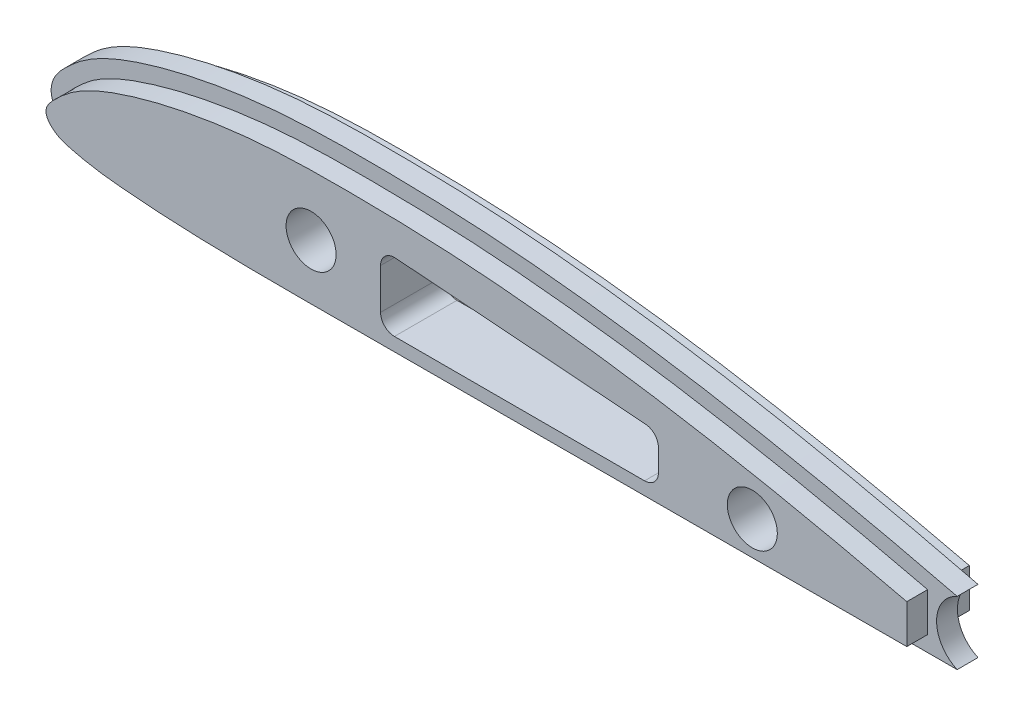
from build123d import *

# Parameters (mm, degrees)
SKETCH3_R               = 3.5
BOSS_EXTRUDE1_DEPTH     = 4
BOSS_EXTRUDE2_DEPTH     = 3
CUT_EXTRUDE1_DEPTH      = 5.0000001
BOSS_EXTRUDE4_DEPTH     = 3
BOSS_EXTRUDE5_DEPTH     = 3
SKETCH9_R               = 3.6
CUT_EXTRUDE2_DEPTH      = 9
CUT_EXTRUDE3_DEPTH      = 4.0000001
CUT_EXTRUDE3_DEPTH_BACK = 7.0000001
SKETCH11_W              = 2.167917732
SKETCH11_H              = 7.161417813
CUT_EXTRUDE6_DEPTH      = 3
SKETCH12_W              = 2.167917732
SKETCH12_H              = 7.161417813
CUT_EXTRUDE7_DEPTH      = 3
CUT_EXTRUDE9_DEPTH      = 3
CUT_EXTRUDE10_DEPTH     = 3


with BuildPart() as part:
    # Sketch3 → Boss-Extrude1 (new body)
    with BuildSketch(Plane.XY.offset(36)):
        with BuildLine():
            Line((-17.507687929, 7.098598456), (-17.507687929, -2.034015736))
            add(Edge.make_bspline(
                [(-17.507687929, -2.034015736), (-17.59710145, -2.034174747), (-23.946393618, -2.045470231), (-36.555421714, -2.068518218), (-52.204726192, -2.095858601), (-64.724293502, -2.119042278), (-74.11406586, -2.136122756), (-83.503466045, -2.154479254), (-92.895603229, -2.167303148), (-100.715063704, -2.181150618), (-106.975936848, -2.203805028), (-111.680744165, -2.207091169), (-116.392596798, -2.178542612), (-121.113091521, -2.10023992), (-125.84321921, -1.945988731), (-129.78756227, -1.737082235), (-132.952810944, -1.498805031), (-135.299204798, -1.298598743), (-137.306246818, -1.094956387), (-138.941018346, -0.85883569), (-140.167865234, -0.63812983), (-141.388343948, -0.367024517), (-142.50781202, -0.106908319), (-143.619879769, 0.187407287), (-144.573251274, 0.566727136), (-145.318542092, 0.960640819), (-146.004517518, 1.453076063), (-146.618651979, 2.013419046), (-147.105315384, 2.593490807), (-147.457347193, 3.170908063), (-147.683742099, 3.645438142), (-147.875151792, 4.283340334), (-147.943241407, 4.925327448), (-147.890465513, 5.612652503), (-147.673433661, 6.400721917), (-147.29794551, 7.135095795), (-146.804153318, 7.818485275), (-146.309832983, 8.377271541), (-145.667480337, 9.017060049), (-144.93409978, 9.693990784), (-143.927837205, 10.555388137), (-142.850562114, 11.332410028), (-141.728789168, 12.023225149), (-140.222179028, 12.824770903), (-138.312181755, 13.673340422), (-136.004938901, 14.51973015), (-133.704333622, 15.252810704), (-131.381472985, 15.913774987), (-128.258181422, 16.687146597), (-124.336161455, 17.472514733), (-119.600616416, 18.190219581), (-114.823127608, 18.671875466), (-108.462225557, 19.005447079), (-100.578503662, 19.032147683), (-91.132523886, 18.843085355), (-81.669646013, 18.277649651), (-69.12546009, 17.049566382), (-53.530845898, 14.827338822), (-35.297374717, 11.277627721), (-23.330991543, 8.527862214), (-17.507687929, 7.098598456)],
                knots=[0.065344951, 0.065344951, 0.065344951, 0.065344951, 0.066237675, 0.128737675, 0.191237675, 0.222487675, 0.253737675, 0.284987675, 0.316237675, 0.347487675, 0.363112675, 0.378737675, 0.394362675, 0.409987675, 0.425612675, 0.441237675, 0.449050175, 0.456862675, 0.464675175, 0.468581425, 0.472487675, 0.476393925, 0.480300175, 0.484206425, 0.48615955, 0.488112675, 0.4900658, 0.492018925, 0.49397205, 0.494948613, 0.495925175, 0.496901738, 0.4978783, 0.498854863, 0.499831425, 0.50178455, 0.503737675, 0.5056908, 0.507643925, 0.511550175, 0.515456425, 0.519362675, 0.523268925, 0.527175175, 0.534987675, 0.542800175, 0.550612675, 0.558425175, 0.566237675, 0.581862675, 0.597487675, 0.613112675, 0.628737675, 0.659987675, 0.691237675, 0.722487675, 0.753737675, 0.816237675, 0.878737675, 0.938392724, 0.938392724, 0.938392724, 0.938392724], degree=3))
        make_face()
        with Locations((-107.507687929, 7.999404624)):
            Circle(SKETCH3_R, mode=Mode.SUBTRACT)
    extrude(amount=BOSS_EXTRUDE1_DEPTH)

    # Sketch4 → Boss-Extrude2 (add)
    with BuildSketch(Plane.XY.offset(40)):
        with BuildLine():
            Line((-19.507687929, -0.037521046), (-19.507687929, 5.529173109))
            add(Edge.make_bspline(
                [(-19.507687929, 5.529173109), (-20.443770828, 5.756777807), (-22.351826136, 6.215749211), (-27.174061996, 7.349019512), (-33.978074235, 8.87255681), (-44.677852951, 11.073938952), (-57.330755001, 13.372822355), (-71.009548629, 15.243863732), (-80.79958979, 16.181661516), (-89.608767887, 16.757734528), (-95.488269025, 16.949372948), (-102.350261409, 17.013236255), (-107.257957682, 17.003677137), (-112.169157697, 16.8305791), (-117.092255682, 16.461150925), (-121.035843273, 15.973066987), (-125.976922577, 15.131238489), (-129.943886321, 14.259599111), (-133.888928179, 13.113562747), (-136.893257554, 12.098280948), (-139.389650859, 11.029019517), (-141.383729174, 9.919905225), (-142.798550192, 8.917902508), (-143.868342813, 7.957464114), (-144.686348929, 7.1840502), (-145.20850207, 6.61597777), (-145.597806824, 6.064290391), (-145.812968494, 5.627863129), (-145.949608602, 5.110451824), (-145.917074686, 4.68114777), (-145.781262852, 4.303708219), (-145.631722987, 4.002112103), (-145.322122744, 3.5592561), (-144.843020742, 3.084633274), (-144.08911256, 2.535035347), (-143.008167388, 2.073432454), (-141.620225791, 1.743003025), (-140.162356424, 1.39981262), (-138.700027853, 1.124107097), (-136.748239015, 0.847974469), (-134.301943532, 0.621510039), (-131.368400158, 0.379313114), (-125.498015236, 0.006362829), (-115.695266078, -0.245453373), (-101.968694839, -0.177054014), (-89.220643014, -0.164335562), (-73.530096937, -0.135235118), (-57.83955343, -0.106214113), (-42.149001448, -0.07780996), (-31.361749043, -0.05939132), (-24.468419414, -0.046267759), (-20.517064545, -0.039291678), (-19.507687929, -0.037521046)],
                knots=[0.070561921, 0.070561921, 0.070561921, 0.070561921, 0.080180377, 0.09015591, 0.120020101, 0.149793491, 0.199219015, 0.248395636, 0.287604023, 0.297393127, 0.336534715, 0.346322474, 0.365907652, 0.385530879, 0.395375762, 0.415192461, 0.425184025, 0.445412191, 0.455710779, 0.466190959, 0.477054504, 0.482786727, 0.488945835, 0.494316033, 0.497126416, 0.500187368, 0.502000869, 0.503849971, 0.505020137, 0.507317905, 0.507986558, 0.509023586, 0.510668219, 0.513358348, 0.515715812, 0.519949385, 0.524973188, 0.5299544, 0.534903202, 0.539824123, 0.549630394, 0.559425369, 0.569214167, 0.608355933, 0.657307127, 0.70626328, 0.735636871, 0.813966735, 0.862922864, 0.892296527, 0.921670208, 0.931748157, 0.931748157, 0.931748157, 0.931748157], degree=3))
        make_face()
    extrude(amount=BOSS_EXTRUDE2_DEPTH)

    # Sketch6 → Cut-Extrude1 (cut, through all)
    with BuildSketch(Plane.XY.offset(40)):
        with BuildLine():
            Line((-17.507687929, -2.034015736), (-17.507687929, 7.098598456))
            add(Edge.make_bspline(
                [(-17.507687929, 7.098598456), (-23.330991543, 8.527862214), (-35.297374717, 11.277627721), (-53.530845898, 14.827338822), (-69.12546009, 17.049566382), (-81.669646013, 18.277649651), (-91.132523886, 18.843085355), (-100.578503662, 19.032147683), (-108.462225557, 19.005447079), (-114.823127608, 18.671875466), (-119.600616416, 18.190219581), (-124.336161455, 17.472514733), (-128.258181422, 16.687146597), (-131.381472985, 15.913774987), (-133.704333622, 15.252810704), (-136.004938901, 14.51973015), (-138.312181755, 13.673340422), (-140.222179028, 12.824770903), (-141.728789168, 12.023225149), (-142.850562114, 11.332410028), (-143.927837205, 10.555388137), (-144.93409978, 9.693990784), (-145.667480337, 9.017060049), (-146.309832983, 8.377271541), (-146.804153318, 7.818485275), (-147.29794551, 7.135095795), (-147.673433661, 6.400721917), (-147.890465513, 5.612652503), (-147.943241407, 4.925327448), (-147.875151792, 4.283340334), (-147.683742099, 3.645438142), (-147.457347193, 3.170908063), (-147.105315384, 2.593490807), (-146.618651979, 2.013419046), (-146.004517518, 1.453076063), (-145.318542092, 0.960640819), (-144.573251274, 0.566727136), (-143.619879769, 0.187407287), (-142.50781202, -0.106908319), (-141.388343948, -0.367024517), (-140.167865234, -0.63812983), (-138.941018346, -0.85883569), (-137.306246818, -1.094956387), (-135.299204798, -1.298598743), (-132.952810944, -1.498805031), (-129.78756227, -1.737082235), (-125.84321921, -1.945988731), (-121.113091521, -2.10023992), (-116.392596798, -2.178542612), (-111.680744165, -2.207091169), (-106.975936848, -2.203805028), (-100.715063704, -2.181150618), (-92.895603229, -2.167303148), (-83.503466045, -2.154479254), (-74.11406586, -2.136122756), (-64.724293502, -2.119042278), (-52.204726192, -2.095858601), (-36.555421714, -2.068518218), (-23.946393618, -2.045470231), (-17.59710145, -2.034174747), (-17.507687929, -2.034015736)],
                knots=[0.065344951, 0.065344951, 0.065344951, 0.065344951, 0.125, 0.1875, 0.25, 0.28125, 0.3125, 0.34375, 0.375, 0.390625, 0.40625, 0.421875, 0.4375, 0.4453125, 0.453125, 0.4609375, 0.46875, 0.4765625, 0.48046875, 0.484375, 0.48828125, 0.4921875, 0.49609375, 0.498046875, 0.5, 0.501953125, 0.50390625, 0.504882812, 0.505859375, 0.506835938, 0.5078125, 0.508789062, 0.509765625, 0.51171875, 0.513671875, 0.515625, 0.517578125, 0.51953125, 0.5234375, 0.52734375, 0.53125, 0.53515625, 0.5390625, 0.546875, 0.5546875, 0.5625, 0.578125, 0.59375, 0.609375, 0.625, 0.640625, 0.65625, 0.6875, 0.71875, 0.75, 0.78125, 0.8125, 0.875, 0.9375, 0.938392724, 0.938392724, 0.938392724, 0.938392724], degree=3))
        make_face()
    extrude(amount=-CUT_EXTRUDE1_DEPTH, mode=Mode.SUBTRACT)

    # Sketch7 → Boss-Extrude4 (add)
    with BuildSketch(Plane(origin=(0, 0, 40), x_dir=(-1, 0, 0), z_dir=(0, 0, -1))):
        with BuildLine():
            Line((17.507687929, 7.098598456), (17.507687929, -2.034015736))
            add(Edge.make_bspline(
                [(17.507687929, -2.034015736), (17.59710145, -2.034174747), (23.946393618, -2.045470231), (36.555421714, -2.068518218), (52.204726192, -2.095858601), (64.724293502, -2.119042278), (74.11406586, -2.136122756), (83.503466045, -2.154479254), (92.895603229, -2.167303148), (100.715063704, -2.181150618), (106.975936848, -2.203805028), (111.680744165, -2.207091169), (116.392596798, -2.178542612), (121.113091521, -2.10023992), (125.84321921, -1.945988731), (129.78756227, -1.737082235), (132.952810944, -1.498805031), (135.299204798, -1.298598743), (137.306246818, -1.094956387), (138.941018346, -0.85883569), (140.167865234, -0.63812983), (141.388343948, -0.367024517), (142.50781202, -0.106908319), (143.619879769, 0.187407287), (144.573251274, 0.566727136), (145.318542092, 0.960640819), (146.004517518, 1.453076063), (146.618651979, 2.013419046), (147.105315384, 2.593490807), (147.457347193, 3.170908063), (147.683742099, 3.645438142), (147.875151792, 4.283340334), (147.943241407, 4.925327448), (147.890465513, 5.612652503), (147.673433661, 6.400721917), (147.29794551, 7.135095795), (146.804153318, 7.818485275), (146.309832983, 8.377271541), (145.667480337, 9.017060049), (144.93409978, 9.693990784), (143.927837205, 10.555388137), (142.850562114, 11.332410028), (141.728789168, 12.023225149), (140.222179028, 12.824770903), (138.312181755, 13.673340422), (136.004938901, 14.51973015), (133.704333622, 15.252810704), (131.381472985, 15.913774987), (128.258181422, 16.687146597), (124.336161455, 17.472514733), (119.600616416, 18.190219581), (114.823127608, 18.671875466), (108.462225557, 19.005447079), (100.578503662, 19.032147683), (91.132523886, 18.843085355), (81.669646013, 18.277649651), (69.12546009, 17.049566382), (53.530845898, 14.827338822), (35.297374717, 11.277627721), (23.330991543, 8.527862214), (17.507687929, 7.098598456)],
                knots=[0.065344951, 0.065344951, 0.065344951, 0.065344951, 0.066237675, 0.128737675, 0.191237675, 0.222487675, 0.253737675, 0.284987675, 0.316237675, 0.347487675, 0.363112675, 0.378737675, 0.394362675, 0.409987675, 0.425612675, 0.441237675, 0.449050175, 0.456862675, 0.464675175, 0.468581425, 0.472487675, 0.476393925, 0.480300175, 0.484206425, 0.48615955, 0.488112675, 0.4900658, 0.492018925, 0.49397205, 0.494948613, 0.495925175, 0.496901738, 0.4978783, 0.498854863, 0.499831425, 0.50178455, 0.503737675, 0.5056908, 0.507643925, 0.511550175, 0.515456425, 0.519362675, 0.523268925, 0.527175175, 0.534987675, 0.542800175, 0.550612675, 0.558425175, 0.566237675, 0.581862675, 0.597487675, 0.613112675, 0.628737675, 0.659987675, 0.691237675, 0.722487675, 0.753737675, 0.816237675, 0.878737675, 0.938392724, 0.938392724, 0.938392724, 0.938392724], degree=3))
        make_face()
    extrude(amount=BOSS_EXTRUDE4_DEPTH)

    # Sketch8 → Boss-Extrude5 (add)
    with BuildSketch(Plane(origin=(0, 0, 37), x_dir=(-1, 0, 0), z_dir=(0, 0, -1))):
        with BuildLine():
            Line((19.507687929, 5.529173109), (19.507687929, -0.037521046))
            add(Edge.make_bspline(
                [(19.507687929, -0.037521046), (20.517064545, -0.039291678), (24.468419414, -0.046267759), (31.361749043, -0.05939132), (42.149001448, -0.07780996), (57.83955343, -0.106214113), (73.530096937, -0.135235118), (89.220643014, -0.164335562), (101.968694839, -0.177054014), (115.695266078, -0.245453373), (125.498015236, 0.006362829), (131.368400158, 0.379313114), (134.301943532, 0.621510039), (136.748239015, 0.847974469), (138.700027853, 1.124107097), (140.162356424, 1.39981262), (141.620225791, 1.743003025), (143.008167388, 2.073432454), (144.08911256, 2.535035347), (144.843020742, 3.084633274), (145.322122744, 3.5592561), (145.631722987, 4.002112103), (145.781262852, 4.303708219), (145.917074686, 4.68114777), (145.949608602, 5.110451824), (145.812968494, 5.627863129), (145.597806824, 6.064290391), (145.20850207, 6.61597777), (144.686348929, 7.1840502), (143.868342813, 7.957464114), (142.798550192, 8.917902508), (141.383729174, 9.919905225), (139.389650859, 11.029019517), (136.893257554, 12.098280948), (133.888928179, 13.113562747), (129.943886321, 14.259599111), (125.976922577, 15.131238489), (121.035843273, 15.973066987), (117.092255682, 16.461150925), (112.169157697, 16.8305791), (107.257957682, 17.003677137), (102.350261409, 17.013236255), (95.488269025, 16.949372948), (89.608767887, 16.757734528), (80.79958979, 16.181661516), (71.009548629, 15.243863732), (57.330755001, 13.372822355), (44.677852951, 11.073938952), (33.978074235, 8.87255681), (27.174061996, 7.349019512), (22.351826136, 6.215749211), (20.443770828, 5.756777807), (19.507687929, 5.529173109)],
                knots=[0.070561921, 0.070561921, 0.070561921, 0.070561921, 0.08063987, 0.110013551, 0.139387214, 0.188343343, 0.266673206, 0.296046798, 0.34500295, 0.393954145, 0.43309591, 0.442884709, 0.452679683, 0.462485955, 0.467406876, 0.472355677, 0.47733689, 0.482360692, 0.486594266, 0.48895173, 0.491641859, 0.493286492, 0.49432352, 0.494992173, 0.497289941, 0.498460107, 0.500309209, 0.50212271, 0.505183661, 0.507994045, 0.513364243, 0.519523351, 0.525255574, 0.536119119, 0.546599299, 0.556897887, 0.577126052, 0.587117617, 0.606934315, 0.616779199, 0.636402426, 0.655987604, 0.665775363, 0.704916951, 0.714706054, 0.753914441, 0.803091062, 0.852516587, 0.882289976, 0.912154167, 0.922129701, 0.931748157, 0.931748157, 0.931748157, 0.931748157], degree=3))
        make_face()
    extrude(amount=BOSS_EXTRUDE5_DEPTH)

    # Sketch9 → Cut-Extrude2 (cut)
    with BuildSketch(Plane.XY.offset(43)):
        with Locations((-107.507687928, 7.999404624)):
            Circle(SKETCH9_R)
        with Locations((-43.993853989, 4.999404624)):
            Circle(SKETCH9_R)
        with BuildLine():
            Line((-59.507687929, 1.999404624), (-95.507687929, 1.999404624))
            ThreePointArc((-95.507687929, 1.999404624), (-96.921901491, 2.585191062), (-97.507687929, 3.999404624))
            Line((-97.507687929, 3.999404624), (-97.507687929, 9.843787512))
            ThreePointArc((-97.507687929, 9.843787512), (-96.867989404, 11.309932081), (-95.358108032, 11.838186132))
            Line((-95.358108032, 11.838186132), (-59.358108032, 9.138186132))
            ThreePointArc((-59.358108032, 9.138186132), (-58.04154336, 8.504088988), (-57.507687929, 7.143787512))
            Line((-57.507687929, 7.143787512), (-57.507687929, 3.999404624))
            ThreePointArc((-57.507687929, 3.999404624), (-58.093474366, 2.585191062), (-59.507687929, 1.999404624))
        make_face()
    extrude(amount=-CUT_EXTRUDE2_DEPTH, mode=Mode.SUBTRACT)

    # Sketch10 → Cut-Extrude3 (cut, two sides)
    with BuildSketch(Plane.XY.offset(40)) as cut_extrude3_sk:
        with BuildLine():
            Line((-17.507687928, 7.098598456), (-17.507687929, -2.034015736))
            ThreePointArc((-17.507687929, -2.034015736), (-20.470817902, 2.53229136), (-17.507687928, 7.098598456))
        make_face()
    extrude(amount=CUT_EXTRUDE3_DEPTH, mode=Mode.SUBTRACT)
    extrude(cut_extrude3_sk.sketch, amount=-CUT_EXTRUDE3_DEPTH_BACK, mode=Mode.SUBTRACT)

    # Sketch11 → Cut-Extrude6 (cut)
    with BuildSketch(Plane.XY.offset(43)):
        with Locations((-20.423729075, 3.042058791)):
            Rectangle(SKETCH11_W, SKETCH11_H)
    extrude(amount=-CUT_EXTRUDE6_DEPTH, mode=Mode.SUBTRACT)

    # Sketch12 → Cut-Extrude7 (cut)
    with BuildSketch(Plane(origin=(0, 0, 34), x_dir=(-1, 0, 0), z_dir=(0, 0, -1))):
        with Locations((20.423729075, 3.042058791)):
            Rectangle(SKETCH12_W, SKETCH12_H)
    extrude(amount=-CUT_EXTRUDE7_DEPTH, mode=Mode.SUBTRACT)

    # Sketch14 → Cut-Extrude9 (cut)
    with BuildSketch(Plane(origin=(0, 0, 34), x_dir=(-1, 0, 0), z_dir=(0, 0, -1))):
        with BuildLine():
            ThreePointArc((17.507687929, -2.034015736), (20.470817902, 2.53229136), (17.507687929, 7.098598456))
            add(Edge.make_bspline(
                [(17.507687929, -2.034015736), (17.59710145, -2.034174747), (23.946393618, -2.045470231), (36.555421714, -2.068518218), (52.204726192, -2.095858601), (64.724293502, -2.119042278), (74.11406586, -2.136122756), (83.503466045, -2.154479254), (92.895603229, -2.167303148), (100.715063704, -2.181150618), (106.975936848, -2.203805028), (111.680744165, -2.207091169), (116.392596798, -2.178542612), (121.113091521, -2.10023992), (125.84321921, -1.945988731), (129.78756227, -1.737082235), (132.952810944, -1.498805031), (135.299204798, -1.298598743), (137.306246818, -1.094956387), (138.941018346, -0.85883569), (140.167865234, -0.63812983), (141.388343948, -0.367024517), (142.50781202, -0.106908319), (143.619879769, 0.187407287), (144.573251274, 0.566727136), (145.318542092, 0.960640819), (146.004517518, 1.453076063), (146.618651979, 2.013419046), (147.105315384, 2.593490807), (147.457347193, 3.170908063), (147.683742099, 3.645438142), (147.875151792, 4.283340334), (147.943241407, 4.925327448), (147.890465513, 5.612652503), (147.673433661, 6.400721917), (147.29794551, 7.135095795), (146.804153318, 7.818485275), (146.309832983, 8.377271541), (145.667480337, 9.017060049), (144.93409978, 9.693990784), (143.927837205, 10.555388137), (142.850562114, 11.332410028), (141.728789168, 12.023225149), (140.222179028, 12.824770903), (138.312181755, 13.673340422), (136.004938901, 14.51973015), (133.704333622, 15.252810704), (131.381472985, 15.913774987), (128.258181422, 16.687146597), (124.336161455, 17.472514733), (119.600616416, 18.190219581), (114.823127608, 18.671875466), (108.462225557, 19.005447079), (100.578503662, 19.032147683), (91.132523886, 18.843085355), (81.669646013, 18.277649651), (69.12546009, 17.049566382), (53.530845898, 14.827338822), (35.297374717, 11.277627721), (23.330991543, 8.527862214), (17.507687929, 7.098598456)],
                knots=[0.065344951, 0.065344951, 0.065344951, 0.065344951, 0.066237675, 0.128737675, 0.191237675, 0.222487675, 0.253737675, 0.284987675, 0.316237675, 0.347487675, 0.363112675, 0.378737675, 0.394362675, 0.409987675, 0.425612675, 0.441237675, 0.449050175, 0.456862675, 0.464675175, 0.468581425, 0.472487675, 0.476393925, 0.480300175, 0.484206425, 0.48615955, 0.488112675, 0.4900658, 0.492018925, 0.49397205, 0.494948613, 0.495925175, 0.496901738, 0.4978783, 0.498854863, 0.499831425, 0.50178455, 0.503737675, 0.5056908, 0.507643925, 0.511550175, 0.515456425, 0.519362675, 0.523268925, 0.527175175, 0.534987675, 0.542800175, 0.550612675, 0.558425175, 0.566237675, 0.581862675, 0.597487675, 0.613112675, 0.628737675, 0.659987675, 0.691237675, 0.722487675, 0.753737675, 0.816237675, 0.878737675, 0.938392724, 0.938392724, 0.938392724, 0.938392724], degree=3))
        make_face()
        with BuildLine():
            Line((21.757687941, 5.81437266), (21.757687941, 0.208464097))
            add(Edge.make_bspline(
                [(21.757687941, 0.208464097), (27.435156831, 0.198237258), (39.245251816, 0.177014142), (57.188038047, 0.144947914), (72.519610371, 0.117067237), (84.784903853, 0.093118104), (93.983532581, 0.081910997), (103.183563193, 0.061634203), (110.848171863, 0.033556862), (116.977658443, 0.078635666), (121.573513778, 0.162320748), (126.165497012, 0.320816771), (129.988221505, 0.530667253), (133.040124441, 0.766581949), (135.330728918, 0.963132049), (137.608273151, 1.203102821), (139.485617274, 1.511700539), (140.97036599, 1.846575285), (142.092415878, 2.106767579), (143.178028805, 2.406656418), (144.178209294, 2.868921197), (145.025119587, 3.564950571), (145.677805283, 4.451173318), (145.704380786, 5.443632855), (145.106613017, 6.372987277), (144.337250241, 7.181558722), (143.494137795, 7.960434605), (142.637901868, 8.702728303), (141.422003019, 9.598127217), (139.782147224, 10.546292159), (137.704142654, 11.489019005), (135.562457811, 12.291719911), (132.655200729, 13.234227506), (128.968439239, 14.235896843), (124.473537708, 15.160153644), (119.939924555, 15.874264664), (115.378481833, 16.369087521), (109.269129835, 16.733040761), (101.609617277, 16.788804796), (92.417217291, 16.633004768), (83.240518594, 16.140996306), (74.087860096, 15.291600486), (64.961938249, 14.179657332), (52.841226577, 12.359280984), (38.420408642, 9.620569914), (27.088521553, 7.088063072), (21.757687941, 5.81437266)],
                knots=[0.076126811, 0.076126811, 0.076126811, 0.076126811, 0.132812569, 0.194042822, 0.255273076, 0.285888203, 0.31650333, 0.347118457, 0.377733584, 0.393041148, 0.408348711, 0.423656275, 0.438963838, 0.44661762, 0.454271402, 0.461925183, 0.469578965, 0.473405856, 0.477232747, 0.481059638, 0.484886529, 0.48871342, 0.49254031, 0.496367201, 0.500194092, 0.504020983, 0.507847874, 0.511674765, 0.515501656, 0.523155437, 0.530809219, 0.538463001, 0.546116783, 0.561424346, 0.57673191, 0.592039473, 0.607347037, 0.6226546, 0.653269727, 0.683884854, 0.714499981, 0.745115108, 0.775730235, 0.806345362, 0.867575616, 0.922322514, 0.922322514, 0.922322514, 0.922322514], degree=3))
        make_face(mode=Mode.SUBTRACT)
    extrude(amount=-CUT_EXTRUDE9_DEPTH, mode=Mode.SUBTRACT)

    # Sketch15 → Cut-Extrude10 (cut)
    with BuildSketch(Plane.XY.offset(43)):
        with BuildLine():
            ThreePointArc((-17.507687929, 7.098598456), (-20.470817902, 2.53229136), (-17.507687929, -2.034015736))
            add(Edge.make_bspline(
                [(-17.507687929, 7.098598456), (-23.330991543, 8.527862214), (-35.297374717, 11.277627721), (-53.530845898, 14.827338822), (-69.12546009, 17.049566382), (-81.669646013, 18.277649651), (-91.132523886, 18.843085355), (-100.578503662, 19.032147683), (-108.462225557, 19.005447079), (-114.823127608, 18.671875466), (-119.600616416, 18.190219581), (-124.336161455, 17.472514733), (-128.258181422, 16.687146597), (-131.381472985, 15.913774987), (-133.704333622, 15.252810704), (-136.004938901, 14.51973015), (-138.312181755, 13.673340422), (-140.222179028, 12.824770903), (-141.728789168, 12.023225149), (-142.850562114, 11.332410028), (-143.927837205, 10.555388137), (-144.93409978, 9.693990784), (-145.667480337, 9.017060049), (-146.309832983, 8.377271541), (-146.804153318, 7.818485275), (-147.29794551, 7.135095795), (-147.673433661, 6.400721917), (-147.890465513, 5.612652503), (-147.943241407, 4.925327448), (-147.875151792, 4.283340334), (-147.683742099, 3.645438142), (-147.457347193, 3.170908063), (-147.105315384, 2.593490807), (-146.618651979, 2.013419046), (-146.004517518, 1.453076063), (-145.318542092, 0.960640819), (-144.573251274, 0.566727136), (-143.619879769, 0.187407287), (-142.50781202, -0.106908319), (-141.388343948, -0.367024517), (-140.167865234, -0.63812983), (-138.941018346, -0.85883569), (-137.306246818, -1.094956387), (-135.299204798, -1.298598743), (-132.952810944, -1.498805031), (-129.78756227, -1.737082235), (-125.84321921, -1.945988731), (-121.113091521, -2.10023992), (-116.392596798, -2.178542612), (-111.680744165, -2.207091169), (-106.975936848, -2.203805028), (-100.715063704, -2.181150618), (-92.895603229, -2.167303148), (-83.503466045, -2.154479254), (-74.11406586, -2.136122756), (-64.724293502, -2.119042278), (-52.204726192, -2.095858601), (-36.555421714, -2.068518218), (-23.946393618, -2.045470231), (-17.59710145, -2.034174747), (-17.507687929, -2.034015736)],
                knots=[0.065344951, 0.065344951, 0.065344951, 0.065344951, 0.125, 0.1875, 0.25, 0.28125, 0.3125, 0.34375, 0.375, 0.390625, 0.40625, 0.421875, 0.4375, 0.4453125, 0.453125, 0.4609375, 0.46875, 0.4765625, 0.48046875, 0.484375, 0.48828125, 0.4921875, 0.49609375, 0.498046875, 0.5, 0.501953125, 0.50390625, 0.504882812, 0.505859375, 0.506835938, 0.5078125, 0.508789062, 0.509765625, 0.51171875, 0.513671875, 0.515625, 0.517578125, 0.51953125, 0.5234375, 0.52734375, 0.53125, 0.53515625, 0.5390625, 0.546875, 0.5546875, 0.5625, 0.578125, 0.59375, 0.609375, 0.625, 0.640625, 0.65625, 0.6875, 0.71875, 0.75, 0.78125, 0.8125, 0.875, 0.9375, 0.938392724, 0.938392724, 0.938392724, 0.938392724], degree=3))
        make_face()
        with BuildLine():
            Line((-21.757687941, 0.208464097), (-21.757687941, 5.81437266))
            add(Edge.make_bspline(
                [(-21.757687941, 5.81437266), (-27.088521553, 7.088063072), (-38.420408642, 9.620569914), (-52.841226577, 12.359280984), (-64.961938249, 14.179657332), (-74.087860096, 15.291600486), (-83.240518594, 16.140996306), (-92.417217291, 16.633004768), (-101.609617277, 16.788804796), (-109.269129835, 16.733040761), (-115.378481833, 16.369087521), (-119.939924555, 15.874264664), (-124.473537708, 15.160153644), (-128.968439239, 14.235896843), (-132.655200729, 13.234227506), (-135.562457811, 12.291719911), (-137.704142654, 11.489019005), (-139.782147224, 10.546292159), (-141.422003019, 9.598127217), (-142.637901868, 8.702728303), (-143.494137795, 7.960434605), (-144.337250241, 7.181558722), (-145.106613017, 6.372987277), (-145.704380786, 5.443632855), (-145.677805283, 4.451173318), (-145.025119587, 3.564950571), (-144.178209294, 2.868921197), (-143.178028805, 2.406656418), (-142.092415878, 2.106767579), (-140.97036599, 1.846575285), (-139.485617274, 1.511700539), (-137.608273151, 1.203102821), (-135.330728918, 0.963132049), (-133.040124441, 0.766581949), (-129.988221505, 0.530667253), (-126.165497012, 0.320816771), (-121.573513778, 0.162320748), (-116.977658443, 0.078635666), (-110.848171863, 0.033556862), (-103.183563193, 0.061634203), (-93.983532581, 0.081910997), (-84.784903853, 0.093118104), (-72.519610371, 0.117067237), (-57.188038047, 0.144947914), (-39.245251816, 0.177014142), (-27.435156831, 0.198237258), (-21.757687941, 0.208464097)],
                knots=[0.076126811, 0.076126811, 0.076126811, 0.076126811, 0.130873709, 0.192103963, 0.22271909, 0.253334217, 0.283949344, 0.314564471, 0.345179598, 0.375794725, 0.391102288, 0.406409852, 0.421717415, 0.437024979, 0.452332542, 0.459986324, 0.467640106, 0.475293887, 0.482947669, 0.48677456, 0.490601451, 0.494428342, 0.498255233, 0.502082123, 0.505909014, 0.509735905, 0.513562796, 0.517389687, 0.521216578, 0.525043469, 0.52887036, 0.536524141, 0.544177923, 0.551831705, 0.559485487, 0.57479305, 0.590100614, 0.605408177, 0.62071574, 0.651330867, 0.681945994, 0.712561121, 0.743176248, 0.804406502, 0.865636756, 0.922322514, 0.922322514, 0.922322514, 0.922322514], degree=3))
        make_face(mode=Mode.SUBTRACT)
    extrude(amount=-CUT_EXTRUDE10_DEPTH, mode=Mode.SUBTRACT)


solid = part.part
